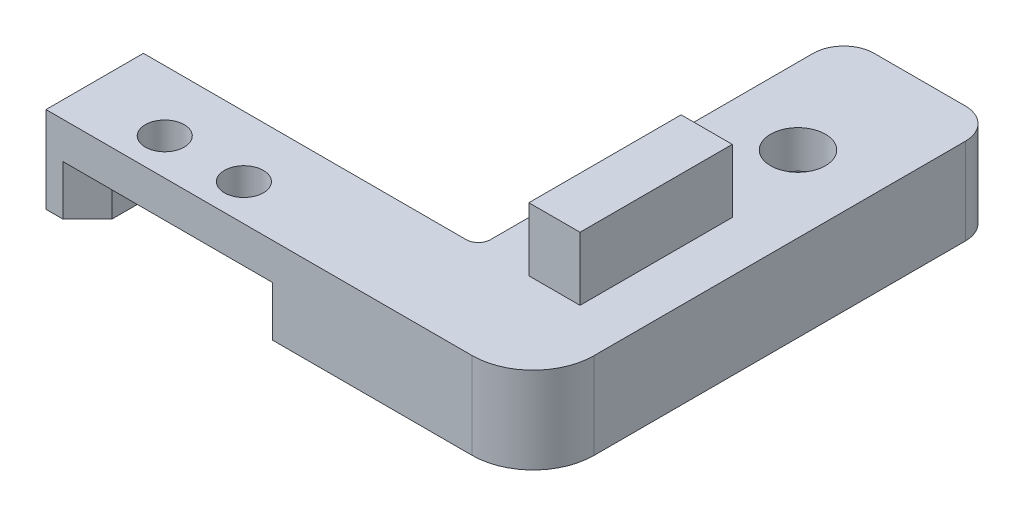
from build123d import *

# Parameters (mm, degrees)
BOSS_EXTRUDE1_DEPTH            = 7.1
SKETCH2_W                      = 4.2
SKETCH2_H                      = 12.5
BOSS_EXTRUDE2_DEPTH            = 5.2
CBORE_FOR_M4_SHCS1_D           = 4.5
CBORE_FOR_M4_SHCS1_CBORE_D     = 8
CBORE_FOR_M4_SHCS1_CBORE_DEPTH = 4
F_3_2_3_2_DIAMETER_HOLE1_D     = 3.2
SKETCH7_W                      = 13.2
SKETCH7_H                      = 8
CUT_EXTRUDE1_DEPTH             = 4.1
FILLET1_R                      = 5
FILLET2_R                      = 2.5
FILLET3_R                      = 1
CHAMFER1_SIZE                  = 2


with BuildPart() as part:
    # Sketch1 → Boss-Extrude1 (new body)
    with BuildSketch(Plane(origin=(0, 0, 0), x_dir=(1, 0, 0), z_dir=(0, 1, 0))):
        Polygon((0, 0), (-12.5, 0), (-12.5, -30), (-40, -30), (-40, -38), (-12.5, -38), (0, -38), align=None)
    extrude(amount=BOSS_EXTRUDE1_DEPTH)

    # Sketch2 → Boss-Extrude2 (add)
    with BuildSketch(Plane(origin=(0, 7.1, 0), x_dir=(1, 0, 0), z_dir=(0, 1, 0))):
        with Locations((-6.25, -23.75)):
            Rectangle(SKETCH2_W, SKETCH2_H)
    extrude(amount=BOSS_EXTRUDE2_DEPTH)

    # CBORE for M4 SHCS1 (through all)
    with Locations(Plane.XZ):
        with Locations((-6.25, 10)):
            CounterBoreHole(CBORE_FOR_M4_SHCS1_D / 2, CBORE_FOR_M4_SHCS1_CBORE_D / 2, CBORE_FOR_M4_SHCS1_CBORE_DEPTH)

    # Ø3.2 (3.2) Diameter Hole1 (through all)
    with Locations(Plane.XZ):
        with Locations((-33.25, 35), (-26.75, 35)):
            Hole(F_3_2_3_2_DIAMETER_HOLE1_D / 2)

    # Sketch7 → Cut-Extrude1 (cut)
    with BuildSketch(Plane.XZ):
        with Locations((-30, 34)):
            Rectangle(SKETCH7_W, SKETCH7_H)
    extrude(amount=-CUT_EXTRUDE1_DEPTH, mode=Mode.SUBTRACT)

    # Fillet1
    fillet1_edges = [part.edges().sort_by_distance(p)[0] for p in [
        (0, 3.55, 38),
    ]]
    fillet(fillet1_edges, radius=FILLET1_R)

    # Fillet2
    fillet2_edges = [part.edges().sort_by_distance(p)[0] for p in [
        (-12.5, 3.55, 0),
        (0, 3.55, 0),
    ]]
    fillet(fillet2_edges, radius=FILLET2_R)

    # Fillet3
    fillet3_edges = [part.edges().sort_by_distance(p)[0] for p in [
        (-12.5, 3.55, 30),
    ]]
    fillet(fillet3_edges, radius=FILLET3_R)

    # Chamfer1
    chamfer1_edges = [part.edges().sort_by_distance(p)[0] for p in [
        (-23.4, 2.05, 38),
        (-36.6, 2.05, 38),
    ]]
    chamfer(chamfer1_edges, length=CHAMFER1_SIZE)


solid = part.part
